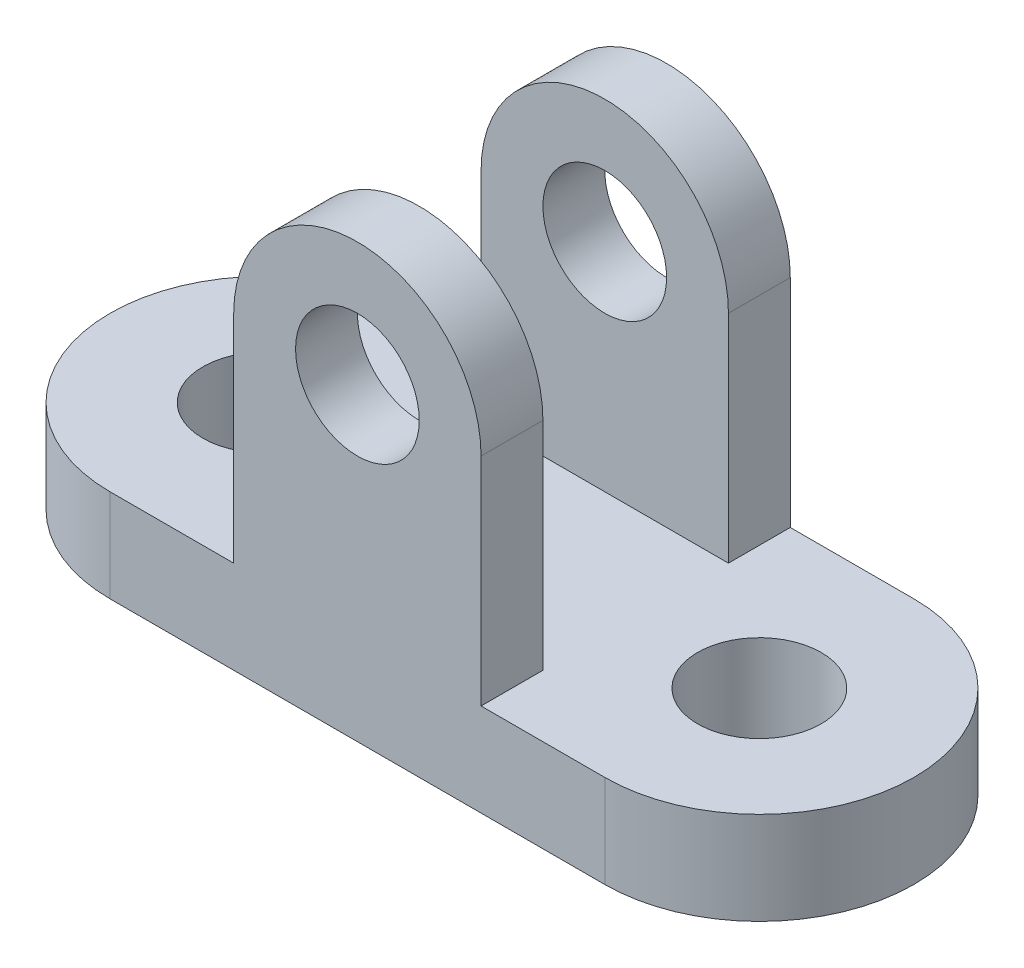
from build123d import *

# Parameters (mm, degrees)
BOSS_EXTRUDE1_DEPTH     = 15
SKETCH2_R               = 10
CUT_EXTRUDE1_DEPTH      = 109.972473589
SKETCH3_W               = 40
SKETCH3_H               = 10
BOSS_EXTRUDE2_DEPTH     = 55
CUT_EXTRUDE2_DEPTH      = 136.738719605
CUT_EXTRUDE2_DEPTH_BACK = 136.738719605


with BuildPart() as part:
    # Sketch1 → Boss-Extrude1 (new body)
    with BuildSketch(Plane(origin=(0, 0, 0), x_dir=(1, 0, 0), z_dir=(0, 1, 0))):
        with BuildLine():
            Line((0, 25), (80, 25))
            ThreePointArc((80, 25), (105, 0), (80, -25))
            Line((80, -25), (0, -25))
            ThreePointArc((0, -25), (-25, 0), (0, 25))
        make_face()
    extrude(amount=BOSS_EXTRUDE1_DEPTH)

    # Sketch2 → Cut-Extrude1 (cut, through all)
    with BuildSketch(Plane(origin=(0, 15, 0), x_dir=(1, 0, 0), z_dir=(0, 1, 0))):
        with Locations(Location((0, 0, 0), (0, 0, 270))):
            Circle(SKETCH2_R)
        with Locations(Location((80, 0, 0), (0, 0, 90))):
            Circle(SKETCH2_R)
    extrude(amount=-CUT_EXTRUDE1_DEPTH, mode=Mode.SUBTRACT)

    # Sketch3 → Boss-Extrude2 (add)
    with BuildSketch(Plane(origin=(0, 15, 0), x_dir=(1, 0, 0), z_dir=(0, 1, 0))):
        with Locations((40, 20)):
            Rectangle(SKETCH3_W, SKETCH3_H)
        with Locations((40, -20)):
            Rectangle(SKETCH3_W, SKETCH3_H)
    extrude(amount=BOSS_EXTRUDE2_DEPTH)

    # Sketch4 → Cut-Extrude2 (cut, two sides)
    with BuildSketch(Plane.XY.offset(25)) as cut_extrude2_sk:
        with BuildLine():
            ThreePointArc((30, 50), (40, 40), (50, 50))
            Line((50, 50), (30, 50))
        make_face()
        with BuildLine():
            Line((30, 50), (50, 50))
            ThreePointArc((50, 50), (40, 60), (30, 50))
        make_face()
        with BuildLine():
            ThreePointArc((40, 70), (54.142135624, 64.142135624), (60, 50))
            Line((60, 50), (60, 70))
            Line((60, 70), (40, 70))
        make_face()
        with BuildLine():
            ThreePointArc((20, 50), (25.857864376, 64.142135624), (40, 70))
            Line((40, 70), (20, 70))
            Line((20, 70), (20, 50))
        make_face()
    extrude(amount=CUT_EXTRUDE2_DEPTH, mode=Mode.SUBTRACT)
    extrude(cut_extrude2_sk.sketch, amount=-CUT_EXTRUDE2_DEPTH_BACK, mode=Mode.SUBTRACT)


solid = part.part
